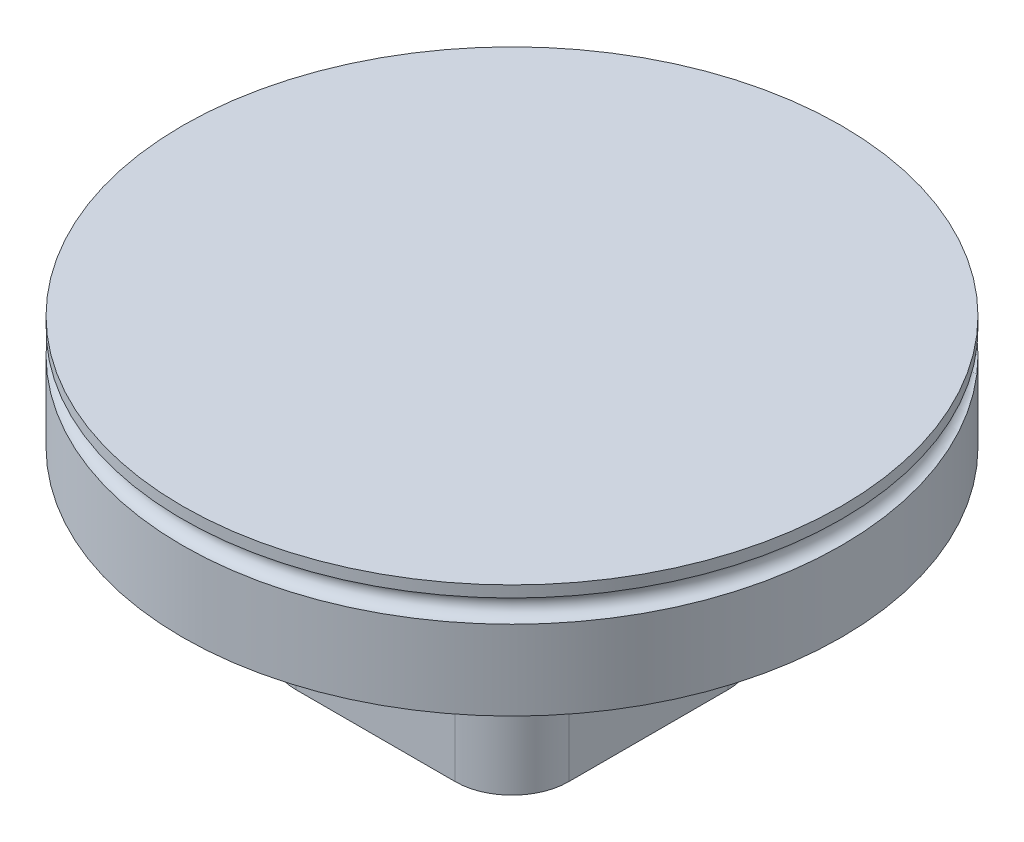
from build123d import *

# Parameters (mm, degrees)
SKETCH1_R           = 29
BOSS_EXTRUDE1_DEPTH = 10
SKETCH2_W           = 24
SKETCH2_H           = 24
SKETCH2_R           = 10
BOSS_EXTRUDE2_DEPTH = 16
SKETCH3_R           = 3
CUT_EXTRUDE1_DEPTH  = 42
FILLET1_R           = 5
FILLET2_R           = 2
SKETCH4_R           = 1


with BuildPart() as part:
    # Sketch1 → Boss-Extrude1 (new body)
    with BuildSketch(Plane(origin=(0, 0, 0), x_dir=(1, 0, 0), z_dir=(0, 1, 0))):
        Circle(SKETCH1_R)
    extrude(amount=BOSS_EXTRUDE1_DEPTH)

    # Sketch2 → Boss-Extrude2 (add)
    with BuildSketch(Plane.XZ):
        Rectangle(SKETCH2_W, SKETCH2_H)
        Circle(SKETCH2_R, mode=Mode.SUBTRACT)
    extrude(amount=BOSS_EXTRUDE2_DEPTH)

    # Sketch3 → Cut-Extrude1 (cut, through all)
    with BuildSketch(Plane(origin=(12, 0, 0), x_dir=(0, 0, -1), z_dir=(1, 0, 0))):
        with Locations((0, -8)):
            Circle(SKETCH3_R)
    extrude(amount=-CUT_EXTRUDE1_DEPTH, mode=Mode.SUBTRACT)

    # Fillet1
    fillet1_edges = [part.edges().sort_by_distance(p)[0] for p in [
        (12, -8, -12),
        (12, -8, 12),
        (-12, -8, 12),
        (-12, -8, -12),
    ]]
    fillet(fillet1_edges, radius=FILLET1_R)

    # Fillet2
    fillet2_edges = [part.edges().sort_by_distance(p)[0] for p in [
        (0, 0, -12),
        (-12, 0, 0),
        (12, 0, 0),
        (0, 0, 12),
        (-10.535533906, 0, -10.535533906),
        (10.535533906, 0, -10.535533906),
        (10.535533906, 0, 10.535533906),
        (-10.535533906, 0, 10.535533906),
    ]]
    fillet(fillet2_edges, radius=FILLET2_R)

    # Sketch4 → Cut-Revolve1 (revolve, cut)
    with BuildSketch(Plane.XY):
        with Locations((-29, 8)):
            Circle(SKETCH4_R)
    revolve(axis=Axis((0, 0, 0), (0, 1, 0)), mode=Mode.SUBTRACT)


solid = part.part
